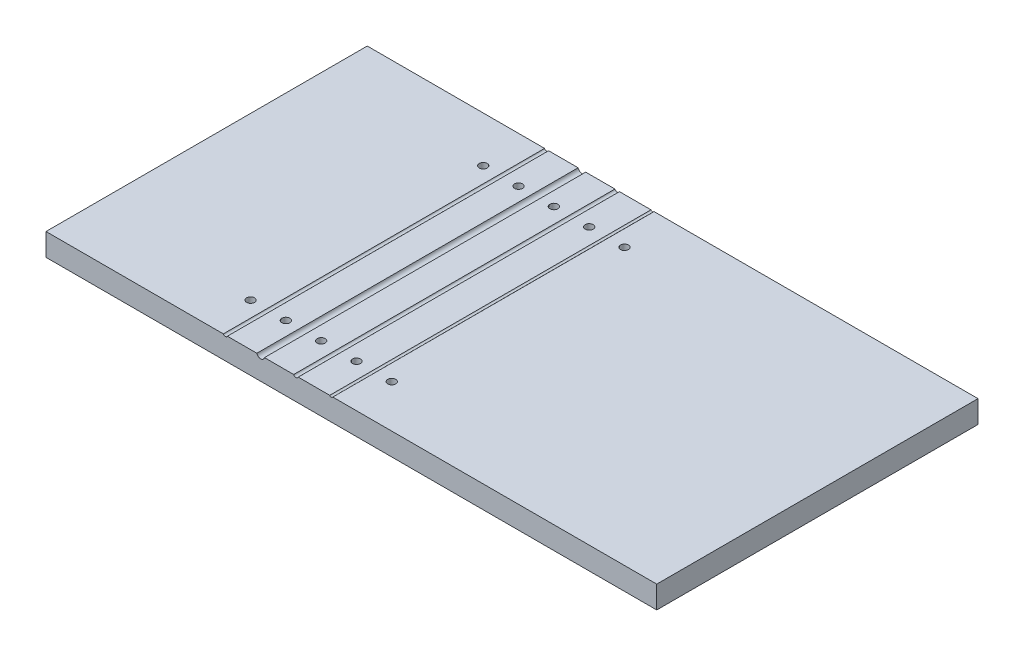
from build123d import *

# Parameters (mm, degrees)
SKETCH1_W             = 173
SKETCH1_H             = 91
BOSS_EXTRUDE1_DEPTH   = 6.35
SKETCH2_R             = 0.6223
SKETCH2_R_2           = 1.1
SKETCH2_R_3           = 0.6858
SKETCH2_R_4           = 0.5
CUT_EXTRUDE1_DEPTH    = 92
F_4_40_TAPPED_HOLE1_D = 2.2606


with BuildPart() as part:
    # Sketch1 → Boss-Extrude1 (new body)
    with BuildSketch(Plane(origin=(0, 0, 0), x_dir=(1, 0, 0), z_dir=(0, 1, 0))):
        with Locations((80.120618557, 39.933676976)):
            Rectangle(SKETCH1_W, SKETCH1_H)
    extrude(amount=BOSS_EXTRUDE1_DEPTH)

    # Sketch2 → Cut-Extrude1 (cut, through all)
    with BuildSketch(Plane.XY.offset(5.566323024)):
        with Locations((44.420618557, 6.6)):
            Circle(SKETCH2_R)
        with Locations((54.420618557, 6.6)):
            Circle(SKETCH2_R_2)
        with Locations((64.420618557, 6.6)):
            Circle(SKETCH2_R_3)
        with Locations((74.420618557, 6.6)):
            Circle(SKETCH2_R_4)
    extrude(amount=-CUT_EXTRUDE1_DEPTH, mode=Mode.SUBTRACT)

    # #4-40 Tapped Hole1 (through all)
    with Locations(Plane(origin=(0, 6.35, 0), x_dir=(1, 0, 0), z_dir=(0, 1, 0))):
        with Locations((39.420618557, 72.491246031), (59.420618557, 72.491246031), (49.420618557, 72.491246031), (49.420618557, 6.5743166), (39.420618557, 6.5743166), (59.420618557, 6.5743166), (69.420618557, 72.491246031), (79.420618557, 72.491246031), (69.420618557, 6.5743166), (79.420618557, 6.5743166)):
            Hole(F_4_40_TAPPED_HOLE1_D / 2)


solid = part.part
